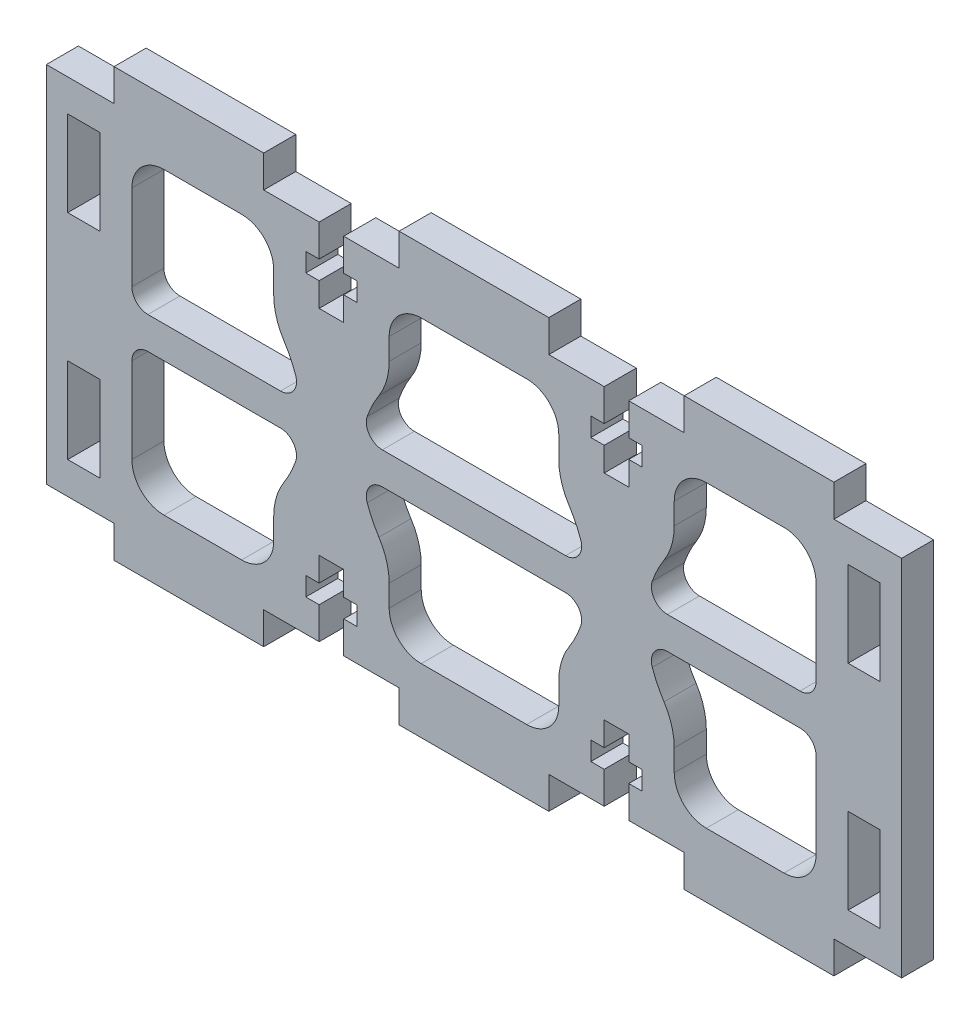
from build123d import *

# Parameters (mm, degrees)
SKETCH1_W           = 80
SKETCH1_H           = 40
BOSS_EXTRUDE1_DEPTH = 1.5
SKETCH3_W           = 6.333333333
SKETCH3_H           = 3
SKETCH3_W_2         = 12.666666667
CUT_EXTRUDE1_DEPTH  = 3
CUT_EXTRUDE3_DEPTH  = 3
SKETCH5_W           = 3
SKETCH5_H           = 8
CUT_EXTRUDE4_DEPTH  = 3
CUT_EXTRUDE6_DEPTH  = 3
FILLET1_R           = 3
BOSS_EXTRUDE2_START = -3
BOSS_EXTRUDE2_DEPTH = 3
FILLET2_R           = 6
BOSS_EXTRUDE3_START = -3
BOSS_EXTRUDE3_DEPTH = 3
FILLET3_R           = 1.5


with BuildPart() as part:
    # Sketch1 → Boss-Extrude1 (new body, symmetric)
    with BuildSketch(Plane.XY):
        with Locations((0, 5.625841184)):
            Rectangle(SKETCH1_W, SKETCH1_H)
    extrude(amount=BOSS_EXTRUDE1_DEPTH, both=True)

    # Sketch3 → Cut-Extrude1 (cut)
    with BuildSketch(Plane(origin=(0, 0, -1.5), x_dir=(-1, 0, 0), z_dir=(0, 0, -1))):
        with Locations((-36.833333334, 24.125841184)):
            Rectangle(SKETCH3_W, SKETCH3_H)
        with Locations((-13.333333334, 24.125841184)):
            Rectangle(SKETCH3_W_2, SKETCH3_H)
        with Locations((13.333333334, 24.125841184)):
            Rectangle(SKETCH3_W_2, SKETCH3_H)
        with Locations((36.833333334, 24.125841184)):
            Rectangle(SKETCH3_W, SKETCH3_H)
        with Locations((-36.833333334, -12.874158816)):
            Rectangle(SKETCH3_W, SKETCH3_H)
        with Locations((-13.333333334, -12.874158816)):
            Rectangle(SKETCH3_W_2, SKETCH3_H)
        with Locations((36.833333334, -12.874158816)):
            Rectangle(SKETCH3_W, SKETCH3_H)
        with Locations((13.333333334, -12.874158816)):
            Rectangle(SKETCH3_W_2, SKETCH3_H)
    extrude(amount=-CUT_EXTRUDE1_DEPTH, mode=Mode.SUBTRACT)

    # Sketch4 → Cut-Extrude3 (cut)
    with BuildSketch(Plane(origin=(0, 0, -1.5), x_dir=(-1, 0, 0), z_dir=(0, 0, -1))):
        Polygon((10.933333333, 17.875841184), (12.183333333, 17.875841184), (12.183333333, 15.625841184), (14.483333333, 15.625841184), (14.483333333, 17.875841184), (15.733333333, 17.875841184), (15.733333333, 19.625841184), (14.483333333, 19.625841184), (14.483333333, 22.625841184), (12.183333333, 22.625841184), (12.183333333, 19.625841184), (10.933333333, 19.625841184), align=None)
        Polygon((-12.183333333, 22.625841184), (-14.483333333, 22.625841184), (-14.483333333, 19.625841184), (-15.733333333, 19.625841184), (-15.733333333, 17.875841184), (-14.483333333, 17.875841184), (-14.483333333, 15.625841184), (-12.183333333, 15.625841184), (-12.183333333, 17.875841184), (-10.933333333, 17.875841184), (-10.933333333, 19.625841184), (-12.183333333, 19.625841184), align=None)
        Polygon((-10.933333333, -6.624158816), (-12.183333333, -6.624158816), (-12.183333333, -4.374158816), (-14.483333333, -4.374158816), (-14.483333333, -6.624158816), (-15.733333333, -6.624158816), (-15.733333333, -8.374158816), (-14.483333333, -8.374158816), (-14.483333333, -11.374158816), (-12.183333333, -11.374158816), (-12.183333333, -8.374158816), (-10.933333333, -8.374158816), align=None)
        Polygon((12.183333333, -11.374158816), (14.483333333, -11.374158816), (14.483333333, -8.374158816), (15.733333333, -8.374158816), (15.733333333, -6.624158816), (14.483333333, -6.624158816), (14.483333333, -4.374158816), (12.183333333, -4.374158816), (12.183333333, -6.624158816), (10.933333333, -6.624158816), (10.933333333, -8.374158816), (12.183333333, -8.374158816), align=None)
    extrude(amount=-CUT_EXTRUDE3_DEPTH, mode=Mode.SUBTRACT)

    # Sketch5 → Cut-Extrude4 (cut)
    with BuildSketch(Plane(origin=(0, 0, -1.5), x_dir=(-1, 0, 0), z_dir=(0, 0, -1))):
        with Locations((36.5, -4.374158816)):
            Rectangle(SKETCH5_W, SKETCH5_H)
        with Locations((36.5, 15.625841184)):
            Rectangle(SKETCH5_W, SKETCH5_H)
        with Locations((-36.5, 15.625841184)):
            Rectangle(SKETCH5_W, SKETCH5_H)
        with Locations((-36.5, -4.374158816)):
            Rectangle(SKETCH5_W, SKETCH5_H)
    extrude(amount=-CUT_EXTRUDE4_DEPTH, mode=Mode.SUBTRACT)

    # Sketch7 → Cut-Extrude6 (cut)
    with BuildSketch(Plane.XY.offset(1.5)):
        Polygon((-32, 19.625841184), (-32, -8.374158816), (-18.733333333, -8.374158816), (-18.733333333, -1.374158816), (-7.933333333, -1.374158816), (-7.933333333, -8.374158816), (7.933333333, -8.374158816), (7.933333333, -1.374158816), (18.733333333, -1.374158816), (18.733333333, -8.374158816), (32, -8.374158816), (32, 19.625841184), (18.733333333, 19.625841184), (18.733333333, 12.625841184), (7.933333333, 12.625841184), (7.933333333, 19.625841184), (-7.933333333, 19.625841184), (-7.933333333, 12.625841184), (-18.733333333, 12.625841184), (-18.733333333, 19.625841184), align=None)
    extrude(amount=-CUT_EXTRUDE6_DEPTH, mode=Mode.SUBTRACT)

    # Fillet1
    fillet1_edges = [part.edges().sort_by_distance(p)[0] for p in [
        (-32, 19.625841184, 0),
        (-18.733333333, 19.625841184, 0),
        (-7.933333333, 19.625841184, 0),
        (7.933333333, 19.625841184, 0),
        (18.733333333, 19.625841184, 0),
        (32, 19.625841184, 0),
        (32, -8.374158816, 0),
        (18.733333333, -8.374158816, 0),
        (7.933333333, -8.374158816, 0),
        (-7.933333333, -8.374158816, 0),
        (-18.733333333, -8.374158816, 0),
        (-32, -8.374158816, 0),
    ]]
    fillet(fillet1_edges, radius=FILLET1_R)

    # Sketch8 → Boss-Extrude2 (add)
    with BuildSketch(Plane.XY.offset(1.5).offset(BOSS_EXTRUDE2_START)):
        with BuildLine():
            Line((-18.733333333, 12.625841184), (-7.933333333, 12.625841184))
            ThreePointArc((-7.933333333, 12.625841184), (-10.580065112, 5.625841184), (-7.933333333, -1.374158816))
            Line((-7.933333333, -1.374158816), (-18.733333333, -1.374158816))
            ThreePointArc((-18.733333333, -1.374158816), (-16.086601554, 5.625841184), (-18.733333333, 12.625841184))
        make_face()
        with BuildLine():
            Line((7.933333333, 12.625841184), (18.733333333, 12.625841184))
            ThreePointArc((18.733333333, 12.625841184), (16.086601554, 5.625841184), (18.733333333, -1.374158816))
            Line((18.733333333, -1.374158816), (7.933333333, -1.374158816))
            ThreePointArc((7.933333333, -1.374158816), (10.580065112, 5.625841184), (7.933333333, 12.625841184))
        make_face()
    extrude(amount=BOSS_EXTRUDE2_DEPTH)

    # Fillet2
    fillet2_edges = [part.edges().sort_by_distance(p)[0] for p in [
        (-18.733333333, 12.625841184, 0),
        (-7.933333333, 12.625841184, 0),
        (7.933333333, 12.625841184, 0),
        (18.733333333, 12.625841184, 0),
        (18.733333333, -1.374158816, 0),
        (7.933333333, -1.374158816, 0),
        (-7.933333333, -1.374158816, 0),
        (-18.733333333, -1.374158816, 0),
    ]]
    fillet(fillet2_edges, radius=FILLET2_R)

    # Sketch9 → Boss-Extrude3 (add)
    with BuildSketch(Plane.XY.offset(1.5).offset(BOSS_EXTRUDE3_START)):
        with BuildLine():
            Line((-32, 7.125841184), (-16.193473372, 7.125841184))
            ThreePointArc((-16.193473372, 7.125841184), (-16.086601554, 5.625841184), (-16.193473372, 4.125841184))
            Line((-16.193473372, 4.125841184), (-32, 4.125841184))
            Line((-32, 4.125841184), (-32, 7.125841184))
        make_face()
        with BuildLine():
            Line((-10.473193294, 7.125841184), (10.473193294, 7.125841184))
            ThreePointArc((10.473193294, 7.125841184), (10.580065112, 5.625841184), (10.473193294, 4.125841184))
            Line((10.473193294, 4.125841184), (-10.473193294, 4.125841184))
            ThreePointArc((-10.473193294, 4.125841184), (-10.580065112, 5.625841184), (-10.473193294, 7.125841184))
        make_face()
        with BuildLine():
            Line((16.193473372, 7.125841184), (32, 7.125841184))
            Line((32, 7.125841184), (32, 4.125841184))
            Line((32, 4.125841184), (16.193473372, 4.125841184))
            ThreePointArc((16.193473372, 4.125841184), (16.086601554, 5.625841184), (16.193473372, 7.125841184))
        make_face()
    extrude(amount=BOSS_EXTRUDE3_DEPTH)

    # Fillet3
    fillet3_edges = [part.edges().sort_by_distance(p)[0] for p in [
        (-32, 4.125841184, 0),
        (-32, 7.125841184, 0),
        (-16.193473372, 7.125841184, 0),
        (-16.193473372, 4.125841184, 0),
        (-10.473193294, 4.125841184, 0),
        (-10.473193294, 7.125841184, 0),
        (10.473193294, 7.125841184, 0),
        (10.473193294, 4.125841184, 0),
        (16.193473372, 4.125841184, 0),
        (16.193473372, 7.125841184, 0),
        (32, 7.125841184, 0),
        (32, 4.125841184, 0),
    ]]
    fillet(fillet3_edges, radius=FILLET3_R)


solid = part.part
